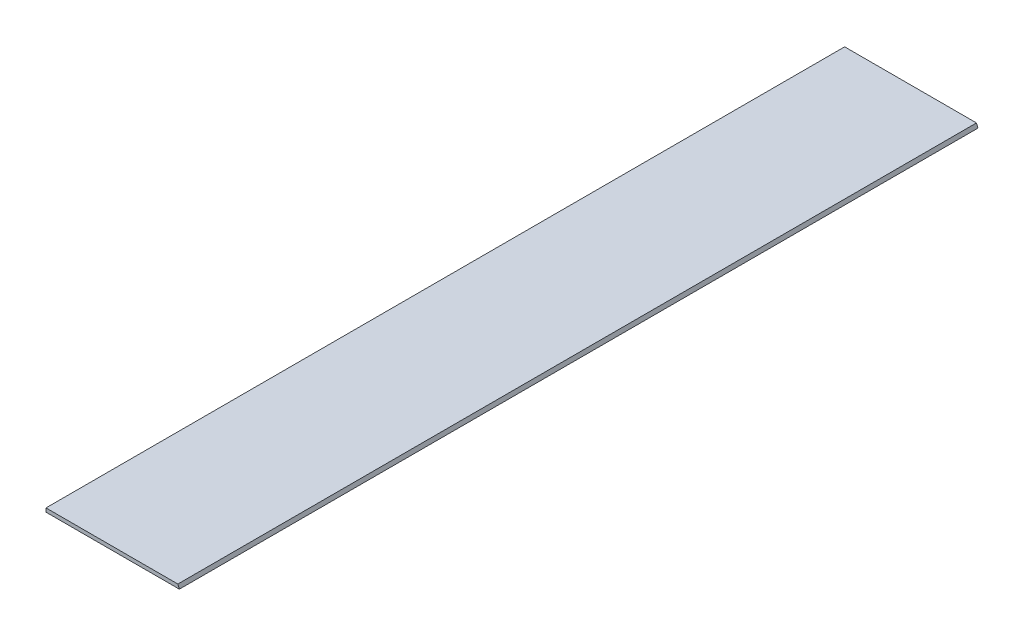
from build123d import *

# Parameters (mm, degrees)
BOSS_EXTRUDE1_DEPTH = 508


with BuildPart() as part:
    # Sketch1 → Boss-Extrude1 (new body)
    with BuildSketch(Plane.XY):
        Polygon((0, 0), (0, 2.3622), (83.857544723, 2.3622), (84.836, 0), align=None)
    extrude(amount=BOSS_EXTRUDE1_DEPTH)


solid = part.part
